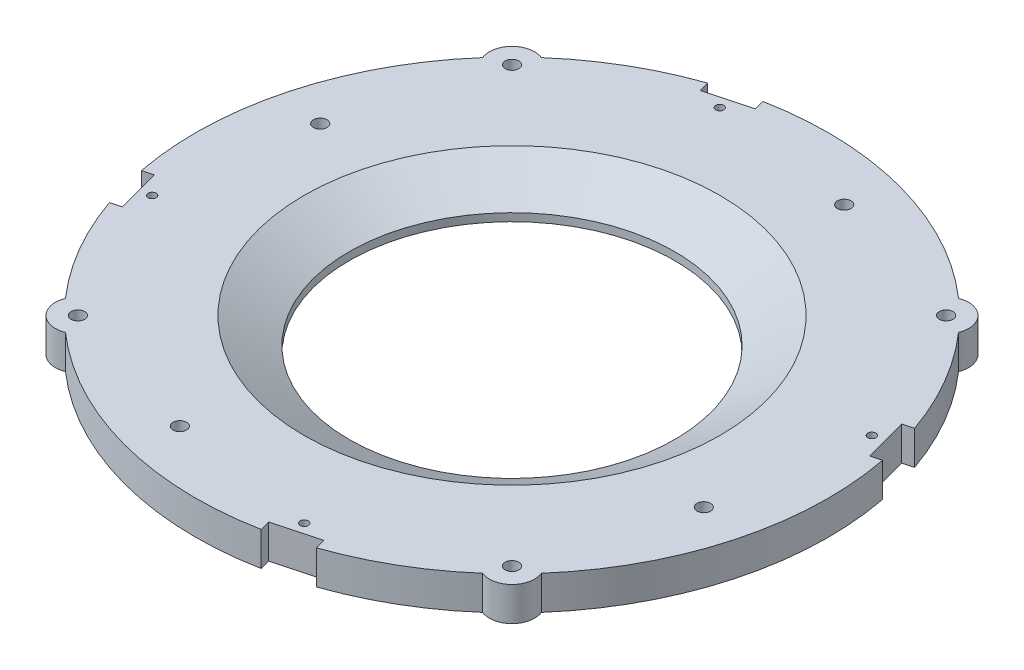
from build123d import *

# Parameters (mm, degrees)
SKETCH1_R           = 1.905
BOSS_EXTRUDE1_DEPTH = 9.525
SKETCH2_R           = 45.72
CUT_EXTRUDE1_DEPTH  = 12.7
SKETCH10_R          = 0.6985
CUT_EXTRUDE5_DEPTH  = 3.175
CIRPATTERN5_COUNT   = 4
CHAMFER1_SIZE       = 12.7
CHAMFER1_SIZE2      = 7.332348419
SKETCH4_R           = 1.905
CUT_EXTRUDE6_DEPTH  = 10.5250001
CIRPATTERN6_COUNT   = 4
SKETCH13_R          = 1.1303
CUT_EXTRUDE7_DEPTH  = 10.5250001
CIRPATTERN7_COUNT   = 4
SKETCH14_W          = 11.95230377
SKETCH14_H          = 12.7
CUT_EXTRUDE8_DEPTH  = 3.175
CIRPATTERN8_COUNT   = 4


with BuildPart() as part:
    # Sketch1 → Boss-Extrude1 (new body)
    with BuildSketch(Plane(origin=(0, 0, 0), x_dir=(1, 0, 0), z_dir=(0, 1, 0))):
        with BuildLine():
            ThreePointArc((-66.860826677, 58.590441679), (-88.9, 0), (-66.860826677, -58.590441679))
            ThreePointArc((-66.860826677, -58.590441679), (-65.466067123, -65.466067123), (-58.590441679, -66.860826677))
            ThreePointArc((-58.590441679, -66.860826677), (0, -88.9), (58.590441679, -66.860826677))
            ThreePointArc((58.590441679, -66.860826677), (65.466067123, -65.466067123), (66.860826677, -58.590441679))
            ThreePointArc((66.860826677, -58.590441679), (88.9, 0), (66.860826677, 58.590441679))
            ThreePointArc((66.860826677, 58.590441679), (65.466067123, 65.466067123), (58.590441679, 66.860826677))
            ThreePointArc((58.590441679, 66.860826677), (0, 88.9), (-58.590441679, 66.860826677))
            ThreePointArc((-58.590441679, 66.860826677), (-65.466067123, 65.466067123), (-66.860826677, 58.590441679))
        make_face()
        with Locations((-60.975939062, 60.975939062)):
            Circle(SKETCH1_R, mode=Mode.SUBTRACT)
        with Locations((60.975939062, 60.975939062)):
            Circle(SKETCH1_R, mode=Mode.SUBTRACT)
        with Locations((60.975939062, -60.975939062)):
            Circle(SKETCH1_R, mode=Mode.SUBTRACT)
        with Locations((-60.975939062, -60.975939062)):
            Circle(SKETCH1_R, mode=Mode.SUBTRACT)
    extrude(amount=BOSS_EXTRUDE1_DEPTH)

    # Sketch2 → Cut-Extrude1 (cut)
    with BuildSketch(Plane(origin=(0, 9.525, 0), x_dir=(1, 0, 0), z_dir=(0, 1, 0))):
        Circle(SKETCH2_R)
    extrude(amount=-CUT_EXTRUDE1_DEPTH, mode=Mode.SUBTRACT)

    # Sketch10 → Cut-Extrude5 (cut)
    with BuildSketch(Plane(origin=(-62.861792847, 0, -62.861792847), x_dir=(0, -1, 0), z_dir=(-0.707106781, 0, -0.707106781))):
        with Locations((-4.826, 0)):
            Circle(SKETCH10_R)
    cut_extrude5 = extrude(amount=-CUT_EXTRUDE5_DEPTH, mode=Mode.SUBTRACT)

    # CirPattern5: Cut-Extrude5 ×4 about axis
    cirpattern5_axis = Axis((0, 0, 0), (0, 1, 0))
    for i in range(1, CIRPATTERN5_COUNT):
        add(cut_extrude5.rotate(cirpattern5_axis, i * 360 / CIRPATTERN5_COUNT), mode=Mode.SUBTRACT)

    # Chamfer1
    chamfer1_edges = [part.edges().sort_by_distance(p)[0] for p in [
        (-45.72, 9.525, 0),
    ]]
    chamfer1_side = [part.faces().sort_by_distance(p)[0] for p in [
        (0, 9.525, -86.385528286),
    ]]
    chamfer(chamfer1_edges, length=CHAMFER1_SIZE, length2=CHAMFER1_SIZE2, reference=chamfer1_side[0])

    # Sketch4 → Cut-Extrude6 (cut, through all)
    with BuildSketch(Plane(origin=(0, 9.525, 0), x_dir=(1, 0, 0), z_dir=(0, 1, 0))):
        with Locations((19.722011237, 73.603547963)):
            Circle(SKETCH4_R)
    cut_extrude6 = extrude(amount=-CUT_EXTRUDE6_DEPTH, mode=Mode.SUBTRACT)

    # CirPattern6: Cut-Extrude6 ×4 about axis
    cirpattern6_axis = Axis((0, 0, 0), (0, 1, 0))
    for i in range(1, CIRPATTERN6_COUNT):
        add(cut_extrude6.rotate(cirpattern6_axis, i * 360 / CIRPATTERN6_COUNT), mode=Mode.SUBTRACT)

    # Sketch13 → Cut-Extrude7 (cut, through all)
    with BuildSketch(Plane(origin=(0, 9.525, 0), x_dir=(1, 0, 0), z_dir=(0, 1, 0))):
        with Locations((-21.365512173, 79.73717696)):
            Circle(SKETCH13_R)
    cut_extrude7 = extrude(amount=-CUT_EXTRUDE7_DEPTH, mode=Mode.SUBTRACT)

    # CirPattern7: Cut-Extrude7 ×4 about axis
    cirpattern7_axis = Axis((0, 0, 0), (0, 1, 0))
    for i in range(1, CIRPATTERN7_COUNT):
        add(cut_extrude7.rotate(cirpattern7_axis, i * 360 / CIRPATTERN7_COUNT), mode=Mode.SUBTRACT)

    # Sketch14 → Cut-Extrude8 (cut)
    with BuildSketch(Plane(origin=(-23.00901311, 0, -85.870805957), x_dir=(0, -1, 0), z_dir=(-0.258819045, 0, -0.965925826))):
        with Locations((-4.621692603, 0)):
            Rectangle(SKETCH14_W, SKETCH14_H)
    cut_extrude8 = extrude(amount=-CUT_EXTRUDE8_DEPTH, mode=Mode.SUBTRACT)

    # CirPattern8: Cut-Extrude8 ×4 about axis
    cirpattern8_axis = Axis((0, 0, 0), (0, 1, 0))
    for i in range(1, CIRPATTERN8_COUNT):
        add(cut_extrude8.rotate(cirpattern8_axis, i * 360 / CIRPATTERN8_COUNT), mode=Mode.SUBTRACT)


solid = part.part
